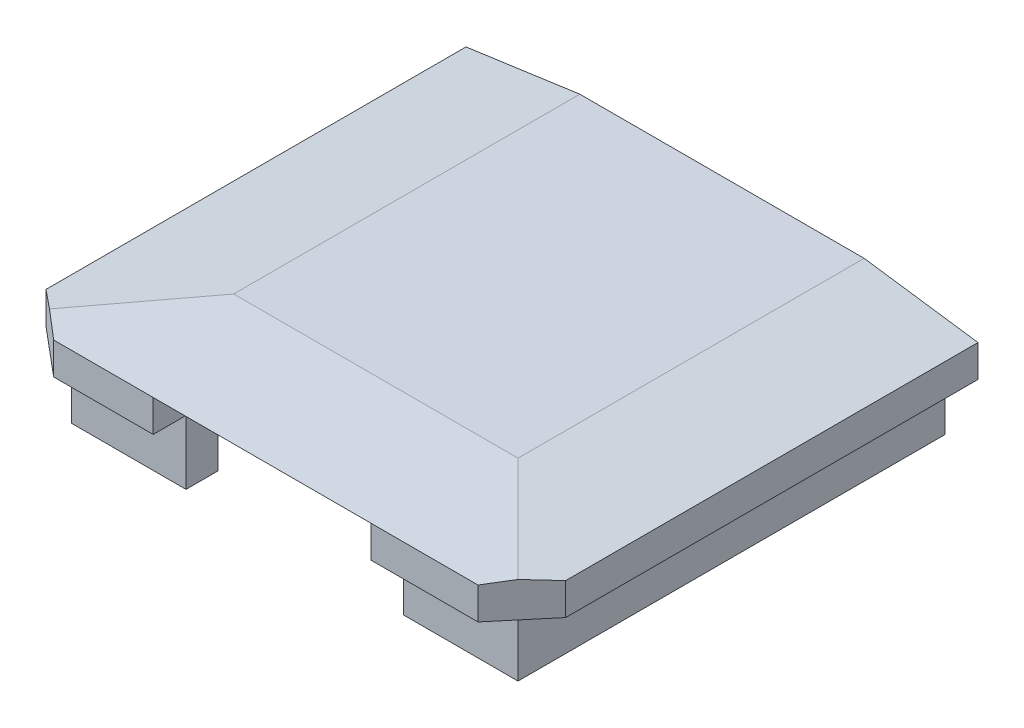
from build123d import *

# Parameters (mm, degrees)
SKETCH1_W             = 32
SKETCH1_H             = 48
BOSS_EXTRUDE1_DEPTH   = 3
BOSS_EXTRUDE2_DEPTH   = 4
CHAMFER1_SIZE         = 1
CHAMFER1_SIZE2        = 7.115369722
CHAMFER1_PART_2_SIZE  = 1
CHAMFER1_PART_2_SIZE2 = 7.115369722
CHAMFER2_SIZE         = 1
CHAMFER2_SIZE2        = 7.115369722
CHAMFER2_PART_2_SIZE  = 1
CHAMFER2_PART_2_SIZE2 = 7.115369722
SKETCH4_W             = 13.6
SKETCH4_H             = 2
CUT_EXTRUDE2_DEPTH    = 7
CHAMFER4_SIZE         = 2.5
CHAMFER4_SIZE2        = 2.979383981
CHAMFER4_PART_2_SIZE  = 2.5
CHAMFER4_PART_2_SIZE2 = 2.979383981
CHAMFER5_SIZE         = 2.5
SKETCH5_W             = 45.346149297
SKETCH5_H             = 21.744132288
CUT_EXTRUDE3_DEPTH    = 10


with BuildPart() as part:
    # Sketch1 → Boss-Extrude1 (new body)
    with BuildSketch(Plane(origin=(0, 0, 0), x_dir=(1, 0, 0), z_dir=(0, 1, 0))):
        Rectangle(SKETCH1_W, SKETCH1_H)
    extrude(amount=BOSS_EXTRUDE1_DEPTH)

    # Sketch2 → Boss-Extrude2 (add)
    with BuildSketch(Plane.XZ):
        Polygon((-13.95, -21.95), (-11.95, -21.95), (-11.95, -19.95), (-11.95, 19.95), (-6.8, 19.95), (-6.8, 21.95), (-13.95, 21.95), align=None)
        Polygon((11.95, -19.95), (11.95, -21.95), (13.95, -21.95), (13.95, 21.95), (6.8, 21.95), (6.8, 19.95), (11.95, 19.95), align=None)
    extrude(amount=BOSS_EXTRUDE2_DEPTH)

    # Chamfer1
    chamfer1_edges = [part.edges().sort_by_distance(p)[0] for p in [
        (0, 3, 24),
    ]]
    chamfer1_side = [part.faces().sort_by_distance(p)[0] for p in [
        (0, 1.5, 24),
    ]]
    chamfer(chamfer1_edges, length=CHAMFER1_SIZE, length2=CHAMFER1_SIZE2, reference=chamfer1_side[0])

    # Chamfer1 part 2
    chamfer1_part_2_edges = [part.edges().sort_by_distance(p)[0] for p in [
        (0, 3, -24),
    ]]
    chamfer1_part_2_side = [part.faces().sort_by_distance(p)[0] for p in [
        (0, 1.5, -24),
    ]]
    chamfer(chamfer1_part_2_edges, length=CHAMFER1_PART_2_SIZE, length2=CHAMFER1_PART_2_SIZE2, reference=chamfer1_part_2_side[0])

    # Chamfer2
    chamfer2_edges = [part.edges().sort_by_distance(p)[0] for p in [
        (16, 3, 0),
    ]]
    chamfer2_side = [part.faces().sort_by_distance(p)[0] for p in [
        (16, 1.439355758, 0),
    ]]
    chamfer(chamfer2_edges, length=CHAMFER2_SIZE, length2=CHAMFER2_SIZE2, reference=chamfer2_side[0])

    # Chamfer2 part 2
    chamfer2_part_2_edges = [part.edges().sort_by_distance(p)[0] for p in [
        (-16, 3, 0),
    ]]
    chamfer2_part_2_side = [part.faces().sort_by_distance(p)[0] for p in [
        (-16, 1.439355758, 0),
    ]]
    chamfer(chamfer2_part_2_edges, length=CHAMFER2_PART_2_SIZE, length2=CHAMFER2_PART_2_SIZE2, reference=chamfer2_part_2_side[0])

    # Sketch4 → Cut-Extrude2 (cut)
    with BuildSketch(Plane.XY.offset(24)):
        with Locations((0, 1)):
            Rectangle(SKETCH4_W, SKETCH4_H)
    extrude(amount=-CUT_EXTRUDE2_DEPTH, mode=Mode.SUBTRACT)

    # Chamfer4
    chamfer4_edges = [part.edges().sort_by_distance(p)[0] for p in [
        (16, 1, 24),
    ]]
    chamfer4_side = [part.faces().sort_by_distance(p)[0] for p in [
        (11.4, 1, 24),
    ]]
    chamfer(chamfer4_edges, length=CHAMFER4_SIZE, length2=CHAMFER4_SIZE2, reference=chamfer4_side[0])

    # Chamfer4 part 2
    chamfer4_part_2_edges = [part.edges().sort_by_distance(p)[0] for p in [
        (-16, 1, 24),
    ]]
    chamfer4_part_2_side = [part.faces().sort_by_distance(p)[0] for p in [
        (-16, 1, 0),
    ]]
    chamfer(chamfer4_part_2_edges, length=CHAMFER4_PART_2_SIZE, length2=CHAMFER4_PART_2_SIZE2, reference=chamfer4_part_2_side[0])

    # Chamfer5
    chamfer5_edges = [part.edges().sort_by_distance(p)[0] for p in [
        (16, 1, -24),
        (-16, 1, -24),
    ]]
    chamfer(chamfer5_edges, length=CHAMFER5_SIZE)

    # Sketch5 → Cut-Extrude3 (cut)
    with BuildSketch(Plane(origin=(0, 3, 0), x_dir=(1, 0, 0), z_dir=(0, 1, 0))):
        with Locations((0.997752906, 15.619993764)):
            Rectangle(SKETCH5_W, SKETCH5_H)
    extrude(amount=-CUT_EXTRUDE3_DEPTH, mode=Mode.SUBTRACT)


solid = part.part
